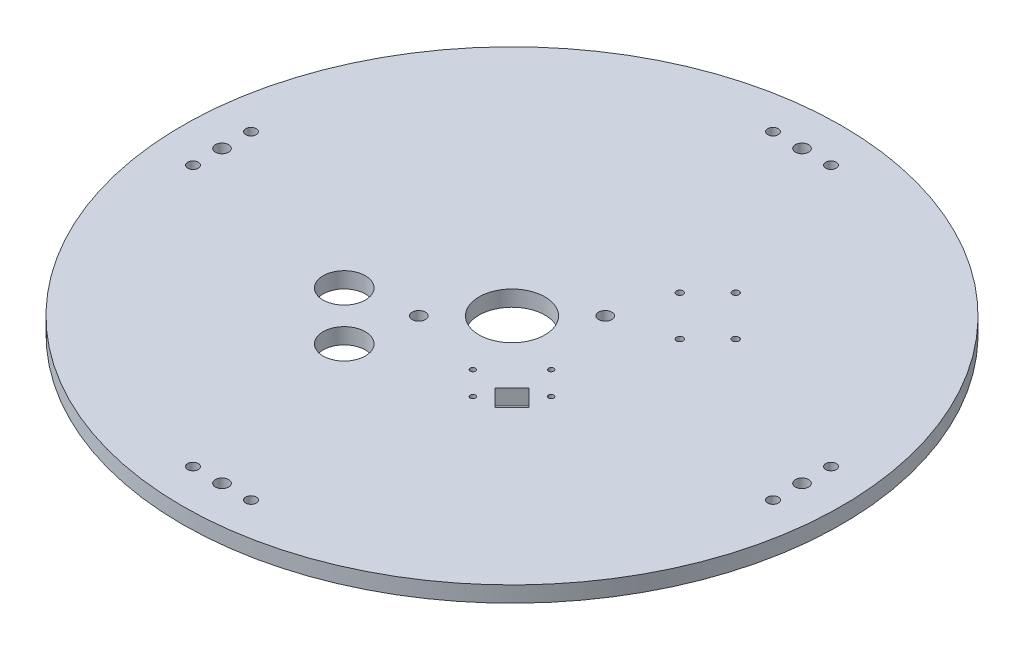
from build123d import *

# Parameters (mm, degrees)
SKETCH1_R           = 125
BOSS_EXTRUDE1_DEPTH = 6
SKETCH2_R           = 2.5
CUT_EXTRUDE1_DEPTH  = 6
SKETCH3_R           = 12.5
CUT_EXTRUDE2_DEPTH  = 6
SKETCH5_R           = 2.5
CUT_EXTRUDE4_DEPTH  = 10
SKETCH7_R           = 1
CUT_EXTRUDE7_DEPTH  = 10
SKETCH8_R           = 2
CUT_EXTRUDE8_DEPTH  = 10
SKETCH9_R           = 1.25
CUT_EXTRUDE9_DEPTH  = 10
SKETCH10_R          = 8
CUT_EXTRUDE10_DEPTH = 10


with BuildPart() as part:
    # Sketch1 → Boss-Extrude1 (new body)
    with BuildSketch(Plane(origin=(0, 0, 0), x_dir=(1, 0, 0), z_dir=(0, 1, 0))):
        Circle(SKETCH1_R)
    extrude(amount=BOSS_EXTRUDE1_DEPTH)

    # Sketch2 → Cut-Extrude1 (cut)
    with BuildSketch(Plane(origin=(0, 0, 0), x_dir=(1, 0, 0), z_dir=(0, 1, 0))):
        with Locations((0, 110)):
            Circle(SKETCH2_R)
        with Locations((110, 0)):
            Circle(SKETCH2_R)
        with Locations((0, -110)):
            Circle(SKETCH2_R)
        with Locations((-110, 0)):
            Circle(SKETCH2_R)
    extrude(amount=CUT_EXTRUDE1_DEPTH, mode=Mode.SUBTRACT)

    # Sketch3 → Cut-Extrude2 (cut)
    with BuildSketch(Plane(origin=(0, 0, 0), x_dir=(1, 0, 0), z_dir=(0, 1, 0))):
        Circle(SKETCH3_R)
    extrude(amount=CUT_EXTRUDE2_DEPTH, mode=Mode.SUBTRACT)

    # Sketch5 → Cut-Extrude4 (cut)
    with BuildSketch(Plane(origin=(0, 0, 0), x_dir=(1, 0, 0), z_dir=(0, 1, 0))):
        with Locations((17.67766953, 17.67766953)):
            Circle(SKETCH5_R)
        with Locations((-17.67766953, -17.67766953)):
            Circle(SKETCH5_R)
    extrude(amount=CUT_EXTRUDE4_DEPTH, mode=Mode.SUBTRACT)

    # Sketch7 → Cut-Extrude7 (cut)
    with BuildSketch(Plane(origin=(0, 0, 0), x_dir=(1, 0, 0), z_dir=(0, 1, 0))):
        with Locations((33.941125497, -19.091883092)):
            Circle(SKETCH7_R)
        with Locations((19.091883092, -33.941125497)):
            Circle(SKETCH7_R)
        with Locations((25.102290732, -10.253048327)):
            Circle(SKETCH7_R)
        with Locations((10.253048327, -25.102290732)):
            Circle(SKETCH7_R)
        Polygon((33.234018716, -26.870057685), (26.870057685, -33.234018716), (20.506096654, -26.870057685), (26.870057685, -20.506096654), align=None)
    extrude(amount=CUT_EXTRUDE7_DEPTH, mode=Mode.SUBTRACT)

    # Sketch8 → Cut-Extrude8 (cut)
    with BuildSketch(Plane(origin=(0, 0, 0), x_dir=(1, 0, 0), z_dir=(0, 1, 0))):
        with Locations((-11, -110)):
            Circle(SKETCH8_R)
        with Locations((11, -110)):
            Circle(SKETCH8_R)
        with Locations((-110, 11)):
            Circle(SKETCH8_R)
        with Locations((-110, -11)):
            Circle(SKETCH8_R)
        with Locations((11, 110)):
            Circle(SKETCH8_R)
        with Locations((-11, 110)):
            Circle(SKETCH8_R)
        with Locations((110, -11)):
            Circle(SKETCH8_R)
        with Locations((110, 11)):
            Circle(SKETCH8_R)
    extrude(amount=CUT_EXTRUDE8_DEPTH, mode=Mode.SUBTRACT)

    # Sketch9 → Cut-Extrude9 (cut)
    with BuildSketch(Plane(origin=(0, 0, 0), x_dir=(1, 0, 0), z_dir=(0, 1, 0))):
        with Locations((34.825008975, 50.027804771)):
            Circle(SKETCH9_R)
        with Locations((24.218407257, 39.421203053)):
            Circle(SKETCH9_R)
        with Locations((39.421203053, 24.218407258)):
            Circle(SKETCH9_R)
        with Locations((50.027804771, 34.825008975)):
            Circle(SKETCH9_R)
    extrude(amount=CUT_EXTRUDE9_DEPTH, mode=Mode.SUBTRACT)

    # Sketch10 → Cut-Extrude10 (cut)
    with BuildSketch(Plane(origin=(0, 0, 0), x_dir=(1, 0, 0), z_dir=(0, 1, 0))):
        with Locations((-22.627416998, -41.012193309)):
            Circle(SKETCH10_R)
        with Locations((-41.012193309, -22.627416998)):
            Circle(SKETCH10_R)
    extrude(amount=CUT_EXTRUDE10_DEPTH, mode=Mode.SUBTRACT)


solid = part.part
